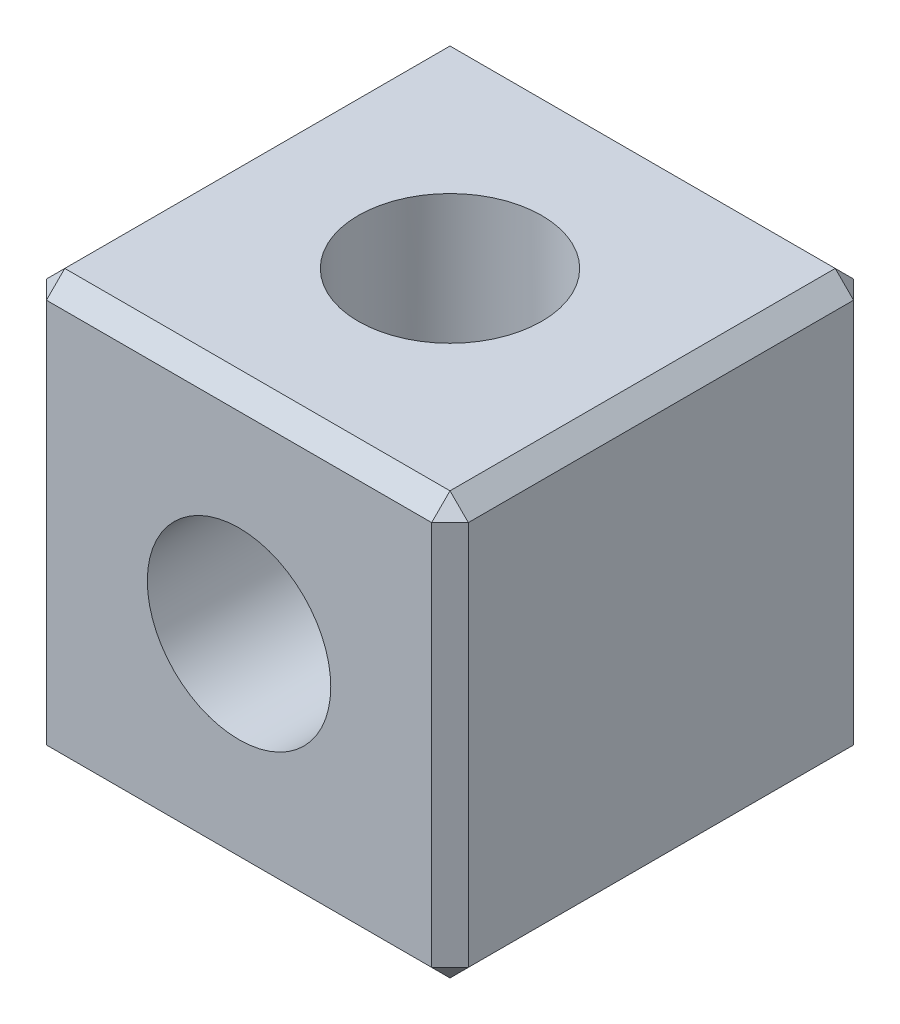
from build123d import *

# Parameters (mm, degrees)
SKETCH1_W           = 23
SKETCH1_H           = 23
BOSS_EXTRUDE1_DEPTH = 23
SKETCH2_R           = 5
CUT_EXTRUDE1_DEPTH  = 23
CUT_EXTRUDE2_DEPTH  = 23
CHAMFER1_SIZE       = 1


with BuildPart() as part:
    # Sketch1 → Boss-Extrude1 (new body)
    with BuildSketch(Plane.XY):
        Rectangle(SKETCH1_W, SKETCH1_H)
    extrude(amount=BOSS_EXTRUDE1_DEPTH)

    # Sketch2 → Cut-Extrude1 (cut)
    with BuildSketch(Plane.XY.offset(23)):
        Circle(SKETCH2_R)
    extrude(amount=-CUT_EXTRUDE1_DEPTH, mode=Mode.SUBTRACT)

    # Sketch3 → Cut-Extrude2 (cut)
    with BuildSketch(Plane(origin=(0, 11.5, 0), x_dir=(1, 0, 0), z_dir=(0, 1, 0))):
        with BuildLine():
            ThreePointArc((5, -11.5), (3.535533906, -7.964466094), (0, -6.5))
            Line((0, -6.5), (0, -16.5))
            ThreePointArc((0, -16.5), (3.535533906, -15.035533906), (5, -11.5))
        make_face()
        with BuildLine():
            Line((0, -16.5), (0, -6.5))
            ThreePointArc((0, -6.5), (-5, -11.5), (0, -16.5))
        make_face()
    extrude(amount=-CUT_EXTRUDE2_DEPTH, mode=Mode.SUBTRACT)

    # Chamfer1
    chamfer1_edges = [part.edges().sort_by_distance(p)[0] for p in [
        (-11.5, 0, 23),
        (0, -11.5, 23),
        (11.5, 0, 23),
        (0, -11.5, 0),
        (-11.5, 0, 0),
        (0, 11.5, 0),
        (11.5, 0, 0),
        (0, 11.5, 23),
        (11.5, -11.5, 11.5),
        (-11.5, -11.5, 11.5),
        (-11.5, 11.5, 11.5),
        (11.5, 11.5, 11.5),
    ]]
    chamfer(chamfer1_edges, length=CHAMFER1_SIZE)


solid = part.part
